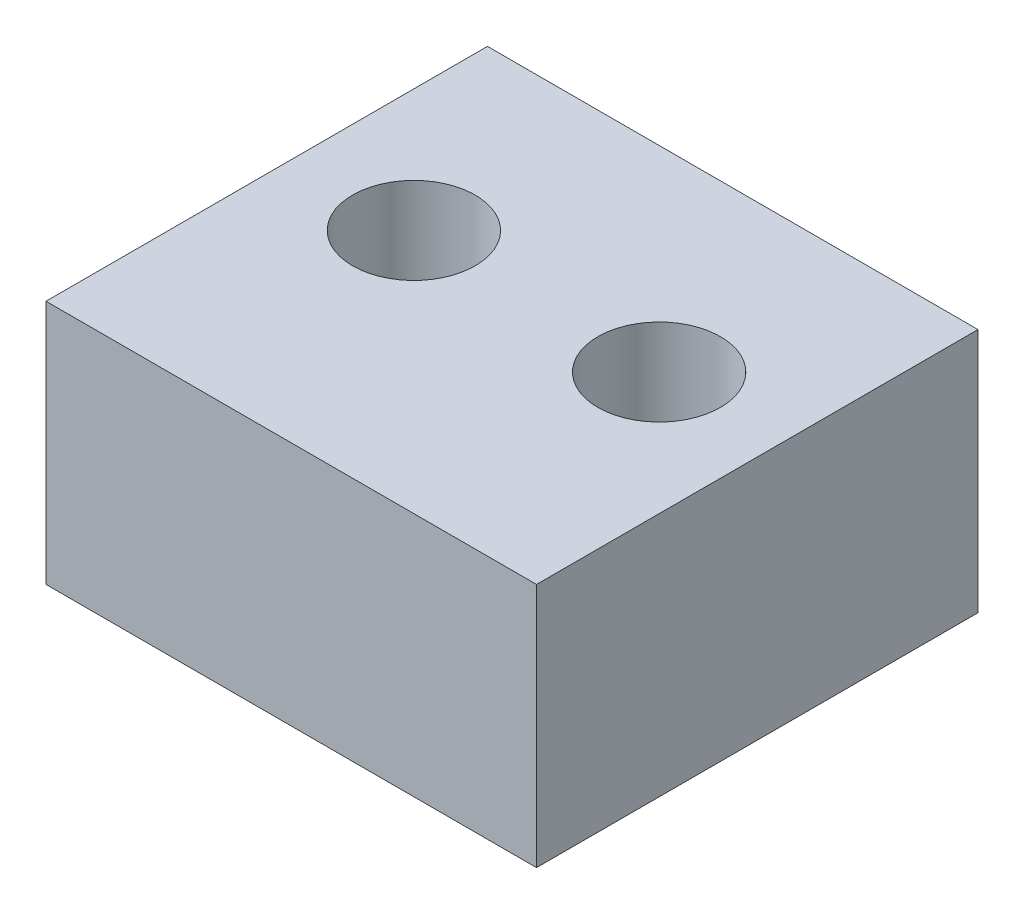
from build123d import *

# Parameters (mm, degrees)
SKETCH1_W                       = 25.4
SKETCH1_H                       = 22.86
BOSS_EXTRUDE1_DEPTH             = 12.7
F_1_4_0_25_DIAMETER_HOLE1_D     = 6.35
F_1_4_0_25_DIAMETER_HOLE1_DEPTH = 12.7


with BuildPart() as part:
    # Sketch1 → Boss-Extrude1 (new body)
    with BuildSketch(Plane(origin=(0, 0, 0), x_dir=(1, 0, 0), z_dir=(0, 1, 0))):
        Rectangle(SKETCH1_W, SKETCH1_H)
    extrude(amount=BOSS_EXTRUDE1_DEPTH)

    # 1/4 (0.25) Diameter Hole1
    with Locations(Plane(origin=(0, 12.7, 0), x_dir=(1, 0, 0), z_dir=(0, 1, 0))):
        with Locations((-6.35, 1.27), (6.35, 1.27)):
            Hole(F_1_4_0_25_DIAMETER_HOLE1_D / 2, depth=F_1_4_0_25_DIAMETER_HOLE1_DEPTH)


solid = part.part
